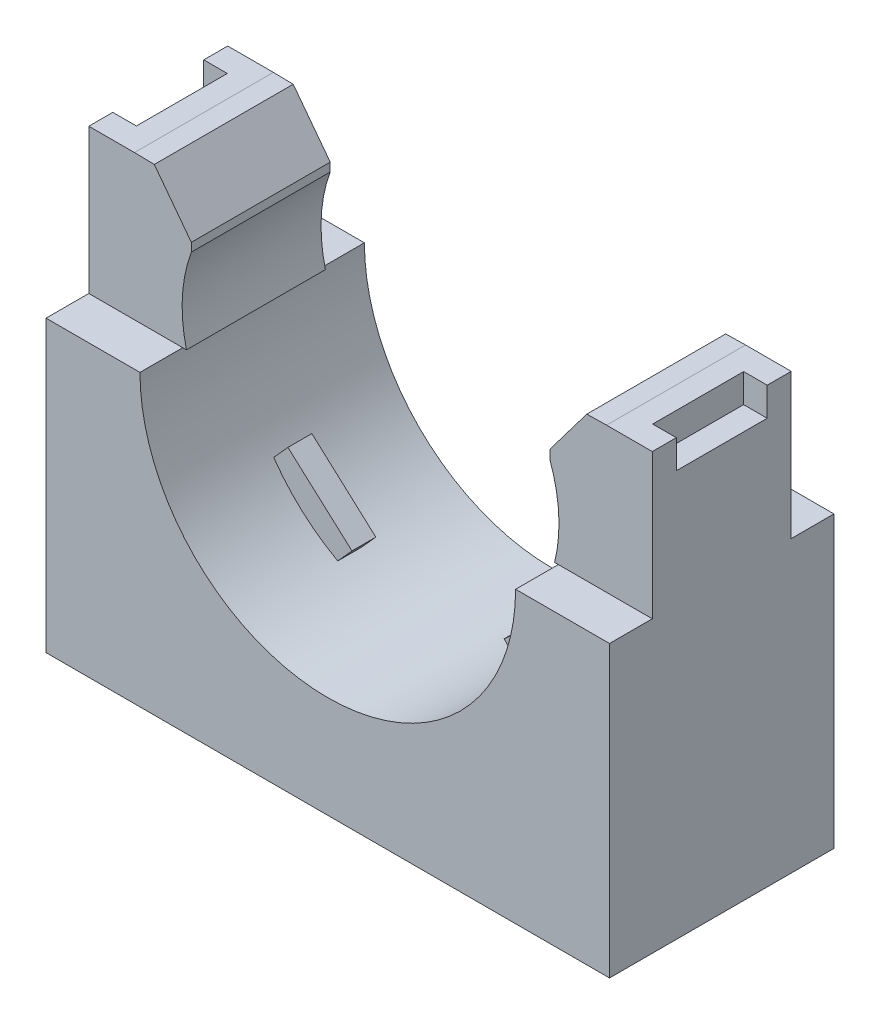
from build123d import *

# Parameters (mm, degrees)
SKETCH1_W               = 29.972
SKETCH1_H               = 23.114
EXTRUDE1_DEPTH          = 11.938
CUT_EXTRUDE1_DEPTH      = 12.938
SKETCH3_W               = 2.27457
SKETCH3_H               = 7.704666667
CUT_EXTRUDE2_DEPTH      = 15.986
CUT_EXTRUDE2_DEPTH_BACK = 15.986
SKETCH4_W               = 28.3845
SKETCH4_H               = 10.3505
CUT_EXTRUDE3_DEPTH      = 0.254
SKETCH5_W               = 1.255132872
SKETCH5_H               = 4.83743
CUT_EXTRUDE4_DEPTH      = 1.524
EXTRUDE2_DEPTH          = 0.635
CUT_EXTRUDE5_DEPTH      = 12.938


with BuildPart() as part:
    # Sketch1 → Extrude1 (new body)
    with BuildSketch(Plane.XY):
        Rectangle(SKETCH1_W, SKETCH1_H)
    extrude(amount=EXTRUDE1_DEPTH)

    # Sketch2 → Cut-Extrude1 (cut, through all)
    with BuildSketch(Plane.XY.offset(11.938)):
        with BuildLine():
            Line((-9.990666667, 3.852333333), (-9.790853333, 3.852333333))
            ThreePointArc((-9.790853333, 3.852333333), (-10.010454448, 6.185541418), (-9.5329375, 8.479895833))
            Line((-9.5329375, 8.479895833), (-9.5329375, 11.504083333))
            Line((-9.5329375, 11.504083333), (-12.557125, 11.557))
            Line((-12.557125, 11.557), (12.557125, 11.557))
            Line((12.557125, 11.557), (9.5329375, 11.504083333))
            Line((9.5329375, 11.504083333), (9.5329375, 8.479895833))
            ThreePointArc((9.5329375, 8.479895833), (10.010454448, 6.185541418), (9.790853333, 3.852333333))
            Line((9.790853333, 3.852333333), (9.990666667, 3.852333333))
            ThreePointArc((9.990666667, 3.852333333), (0, -6.138333333), (-9.990666667, 3.852333333))
        make_face()
    extrude(amount=-CUT_EXTRUDE1_DEPTH, mode=Mode.SUBTRACT)

    # Sketch3 → Cut-Extrude2 (cut, two sides)
    with BuildSketch(Plane(origin=(0, 0, 0), x_dir=(0, 0, -1), z_dir=(1, 0, 0))) as cut_extrude2_sk:
        with Locations((-10.800715, 7.704666667)):
            Rectangle(SKETCH3_W, SKETCH3_H)
        with Locations((-1.137285, 7.704666667)):
            Rectangle(SKETCH3_W, SKETCH3_H)
    extrude(amount=CUT_EXTRUDE2_DEPTH, mode=Mode.SUBTRACT)
    extrude(cut_extrude2_sk.sketch, amount=-CUT_EXTRUDE2_DEPTH_BACK, mode=Mode.SUBTRACT)

    # Sketch4 → Cut-Extrude3 (cut)
    with BuildSketch(Plane.XZ.offset(11.557)):
        with Locations((0, 5.969)):
            Rectangle(SKETCH4_W, SKETCH4_H)
    extrude(amount=-CUT_EXTRUDE3_DEPTH, mode=Mode.SUBTRACT)

    # Sketch5 → Cut-Extrude4 (cut)
    with BuildSketch(Plane(origin=(0, 11.557, 0), x_dir=(1, 0, 0), z_dir=(0, 1, 0))):
        with Locations((-14.358433564, -5.969)):
            Rectangle(SKETCH5_W, SKETCH5_H)
        with Locations((14.358433564, -5.969)):
            Rectangle(SKETCH5_W, SKETCH5_H)
    extrude(amount=-CUT_EXTRUDE4_DEPTH, mode=Mode.SUBTRACT)

    # Sketch6 → Cut-Revolve1 (revolve, cut)
    with BuildSketch(Plane(origin=(0, 0, 5.969), x_dir=(-1, 0, 0), z_dir=(0, 0, -1)), mode=Mode.PRIVATE) as cut_revolve1_sk:
        Polygon((2.54, -11.303), (0, -11.303), (0, -6.223), (4.953, -6.223), (4.953, -8.763), (2.54, -8.763), align=None)
    revolve(cut_revolve1_sk.sketch.rotate(Axis((0, 0, 5.969), (0, -1, 0)), 270), axis=Axis((0, 0, 5.969), (0, -1, 0)), mode=Mode.SUBTRACT)  # turned: the seam where the file's is

    # Sketch7 → Extrude2 (add, symmetric)
    with BuildSketch(Plane(origin=(0, 0, 5.969), x_dir=(-1, 0, 0), z_dir=(0, 0, -1))):
        with BuildLine():
            Line((4.047558738, -4.067217721), (7.45308183, -1.000870956))
            Line((7.45308183, -1.000870956), (8.209636208, -1.841109717))
            ThreePointArc((8.209636208, -1.841109717), (6.685060845, -3.572178903), (4.804113117, -4.907456482))
            Line((4.804113117, -4.907456482), (4.047558738, -4.067217721))
        make_face()
        with BuildLine():
            Line((-4.047558738, -4.067217721), (-4.804113117, -4.907456482))
            ThreePointArc((-4.804113117, -4.907456482), (-6.685060845, -3.572178903), (-8.209636208, -1.841109717))
            Line((-8.209636208, -1.841109717), (-7.45308183, -1.000870956))
            Line((-7.45308183, -1.000870956), (-4.047558738, -4.067217721))
        make_face()
    extrude(amount=EXTRUDE2_DEPTH, both=True)

    # Sketch8 → Cut-Extrude5 (cut, through all)
    with BuildSketch(Plane.XY):
        Polygon((-9.5329375, 11.538527778), (-11.5014375, 11.538527778), (-9.5329375, 8.935027778), align=None)
        Polygon((9.5329375, 11.538527778), (11.5014375, 11.538527778), (9.5329375, 8.935027778), align=None)
    extrude(amount=CUT_EXTRUDE5_DEPTH, mode=Mode.SUBTRACT)


solid = part.part
